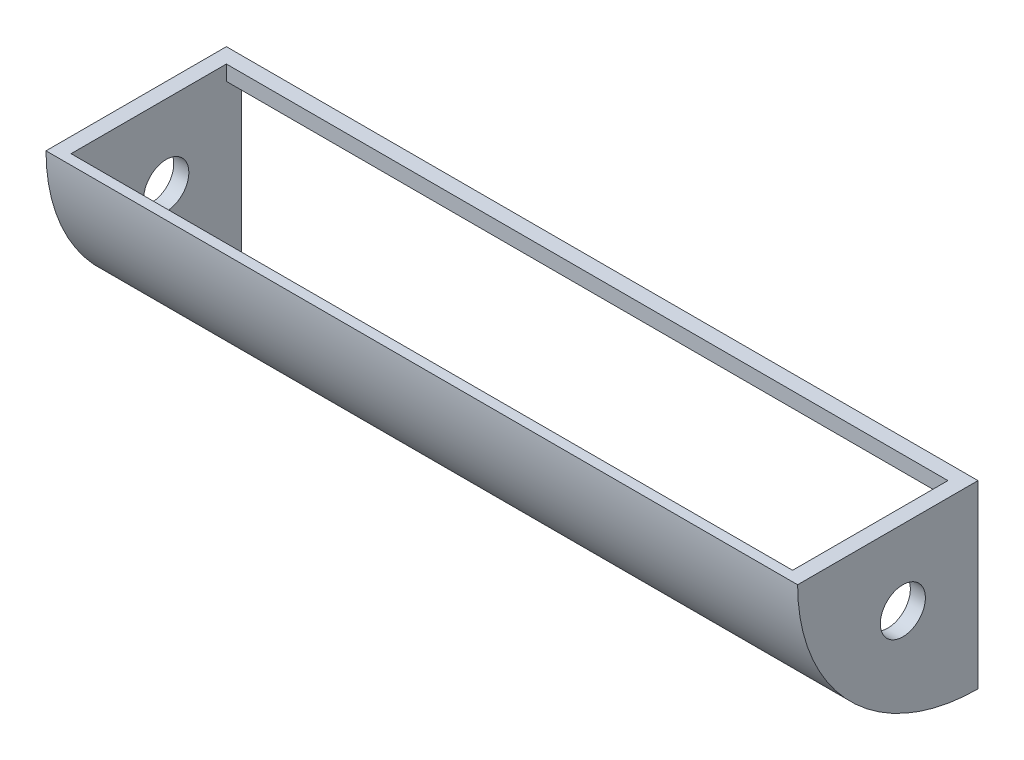
from build123d import *

# Parameters (mm, degrees)
BOSS_EXTRUDE1_DEPTH = 25.4
SKETCH2_W           = 25.4
SKETCH2_H           = 25.4
BOSS_EXTRUDE2_DEPTH = 609.6
SKETCH3_R           = 38.1
CUT_EXTRUDE1_DEPTH  = 609.6


with BuildPart() as part:
    # Sketch1 → Boss-Extrude1 (new body)
    with BuildSketch(Plane(origin=(0, 0, 0), x_dir=(0, 0, -1), z_dir=(1, 0, 0))):
        with BuildLine():
            Line((0, 0), (-304.8, 0))
            ThreePointArc((-304.8, 0), (-215.526146906, -215.526146906), (0, -304.8))
            Line((0, -304.8), (0, 0))
        make_face()
    boss_extrude1 = extrude(amount=BOSS_EXTRUDE1_DEPTH)

    # Sketch2 → Boss-Extrude2 (add)
    with BuildSketch(Plane(origin=(25.4, 0, 0), x_dir=(0, 0, -1), z_dir=(1, 0, 0))):
        with BuildLine():
            Line((-304.8, 0), (-287.848767292, 0))
            ThreePointArc((-287.848767292, 0), (-226.698239846, -177.38325987), (-69.22826613, -279.4))
            Line((-69.22826613, -279.4), (-69.22826613, -296.834107152))
            ThreePointArc((-69.22826613, -296.834107152), (-238.750723053, -189.475941063), (-304.8, 0))
        make_face()
        with Locations((-12.7, -12.7)):
            Rectangle(SKETCH2_W, SKETCH2_H)
    boss_extrude2 = extrude(amount=BOSS_EXTRUDE2_DEPTH)

    # Sketch3 → Cut-Extrude1 (cut)
    with BuildSketch(Plane.ZY):
        with Locations((127, -127)):
            Circle(SKETCH3_R)
    cut_extrude1 = extrude(amount=-CUT_EXTRUDE1_DEPTH, mode=Mode.SUBTRACT)

    # Mirror2: Boss-Extrude2 across plane
    add(boss_extrude2.mirror(Plane(origin=(635, 0, 0), x_dir=(0, 0, 1), z_dir=(1, 0, 0))))

    # Mirror3: Boss-Extrude1 across plane
    add(boss_extrude1.mirror(Plane(origin=(635, 0, 0), x_dir=(0, 0, 1), z_dir=(1, 0, 0))))

    # Mirror4: Cut-Extrude1 across plane
    add(cut_extrude1.mirror(Plane(origin=(635, 0, 0), x_dir=(0, 0, 1), z_dir=(1, 0, 0))), mode=Mode.SUBTRACT)


solid = part.part
